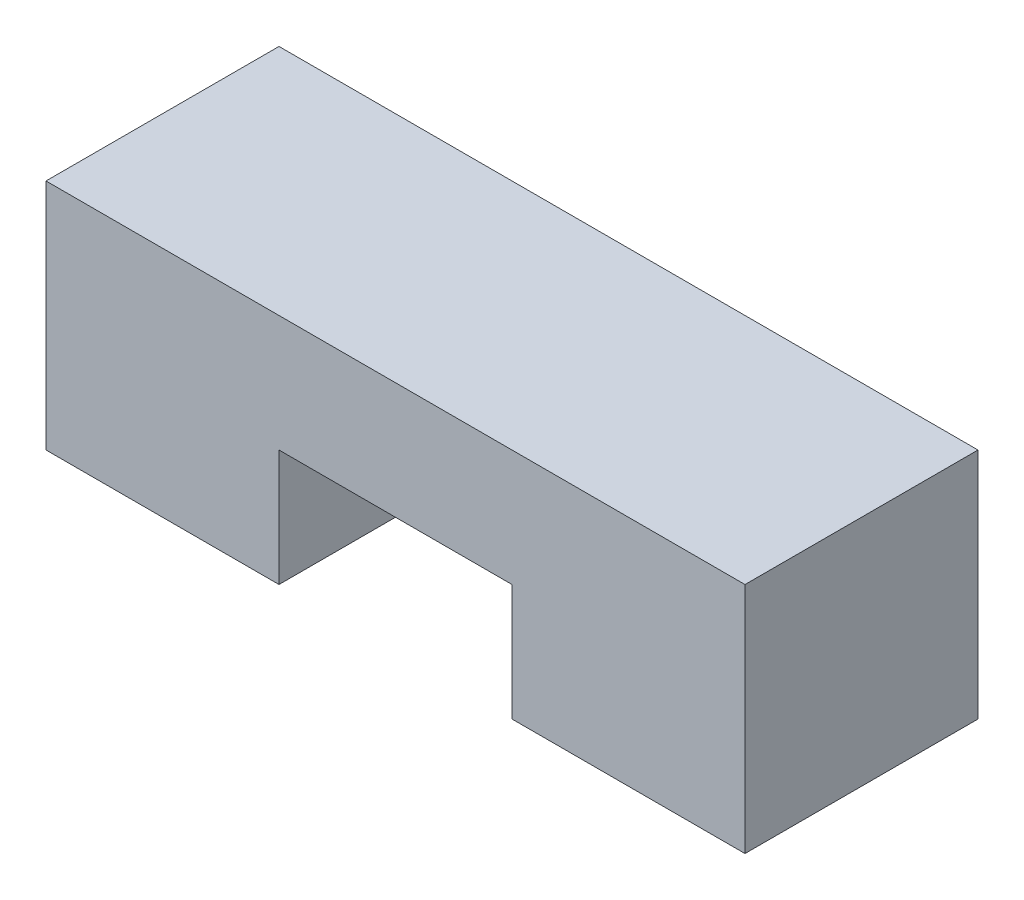
from build123d import *

# Parameters (mm, degrees)
BOSS_EXTRUDE1_DEPTH = 25.4


with BuildPart() as part:
    # Sketch1 → Boss-Extrude1 (new body)
    with BuildSketch(Plane.XY):
        Polygon((25.4, 0), (25.4, 12.7), (50.8, 12.7), (50.8, 0), (76.2, 0), (76.2, 25.4), (0, 25.4), (0, 0), align=None)
    extrude(amount=-BOSS_EXTRUDE1_DEPTH)


solid = part.part
